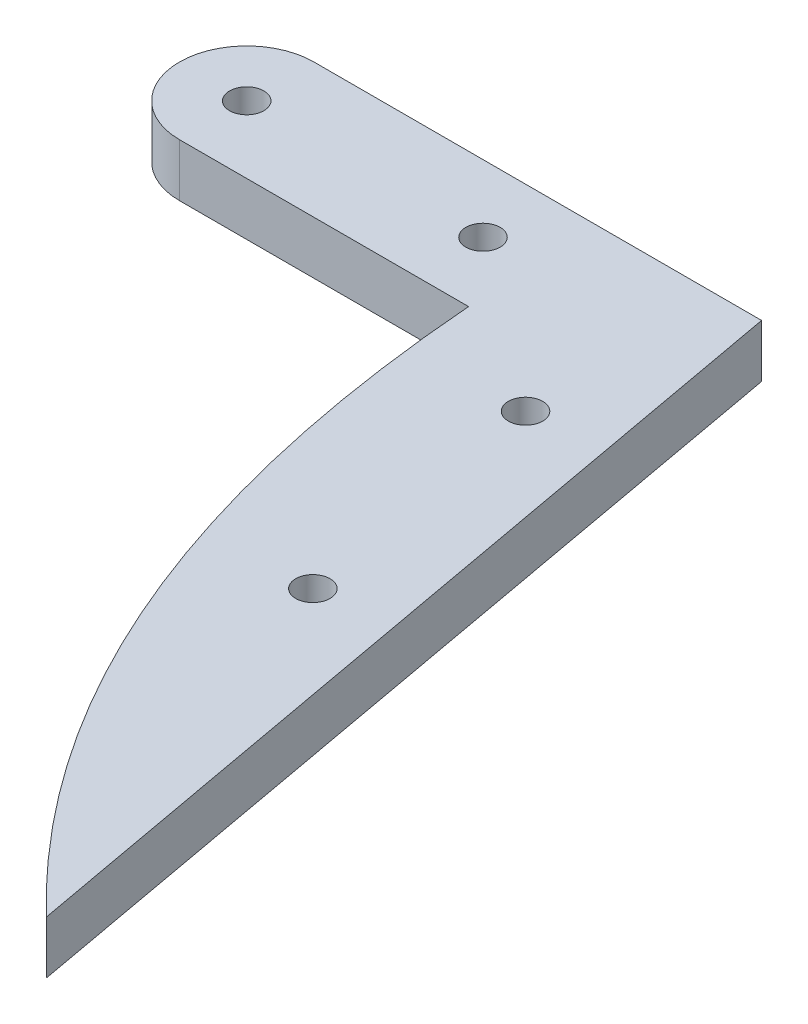
from build123d import *

# Parameters (mm, degrees)
SKETCH1_R           = 1.625
BOSS_EXTRUDE1_DEPTH = 5
BOSS_EXTRUDE2_START = -5
BOSS_EXTRUDE2_DEPTH = 5
SKETCH3_R           = 1.625
CUT_EXTRUDE1_DEPTH  = 30


with BuildPart() as part:
    # Sketch1 → Boss-Extrude1 (new body)
    with BuildSketch(Plane(origin=(0, 0, 0), x_dir=(1, 0, 0), z_dir=(0, 1, 0))):
        with BuildLine():
            Line((11.18, 6.364229765), (-11.18, 6.364229765))
            ThreePointArc((-11.18, 6.364229765), (-17.544229765, 0), (-11.18, -6.364229765))
            Line((-11.18, -6.364229765), (11.18, -6.364229765))
            ThreePointArc((11.18, -6.364229765), (17.544229765, 0), (11.18, 6.364229765))
        make_face()
        with Locations((-11.18, 0)):
            Circle(SKETCH1_R, mode=Mode.SUBTRACT)
        with Locations((11.18, 0)):
            Circle(SKETCH1_R, mode=Mode.SUBTRACT)
    extrude(amount=BOSS_EXTRUDE1_DEPTH)

    # Sketch2 → Boss-Extrude2 (add)
    with BuildSketch(Plane(origin=(0, 5, 0), x_dir=(1, 0, 0), z_dir=(0, 1, 0)).offset(BOSS_EXTRUDE2_START)):
        with BuildLine():
            ThreePointArc((11.18, 6.364229765), (17.544229765, 0), (11.18, -6.364229765))
            Line((11.18, -6.364229765), (16.18, -6.364229765))
            add(Edge.make_bspline(
                [(16.18, -6.364229765), (19.580097968, -50.660653283), (46.22922531, -76.364229765)],
                knots=[0, 0, 0, 0.734976688, 0.734976688, 0.734976688], degree=2))
            Line((46.22922531, -76.364229765), (31.18, 6.364229765))
            Line((31.18, 6.364229765), (11.18, 6.364229765))
        make_face()
    extrude(amount=BOSS_EXTRUDE2_DEPTH)

    # Sketch3 → Cut-Extrude1 (cut)
    with BuildSketch(Plane(origin=(0, 5, 0), x_dir=(1, 0, 0), z_dir=(0, 1, 0))):
        with Locations((27.4505743, -12.246247431)):
            Circle(SKETCH3_R)
        with Locations((31.924922619, -36.842592833)):
            Circle(SKETCH3_R)
    extrude(amount=-CUT_EXTRUDE1_DEPTH, mode=Mode.SUBTRACT)


solid = part.part
